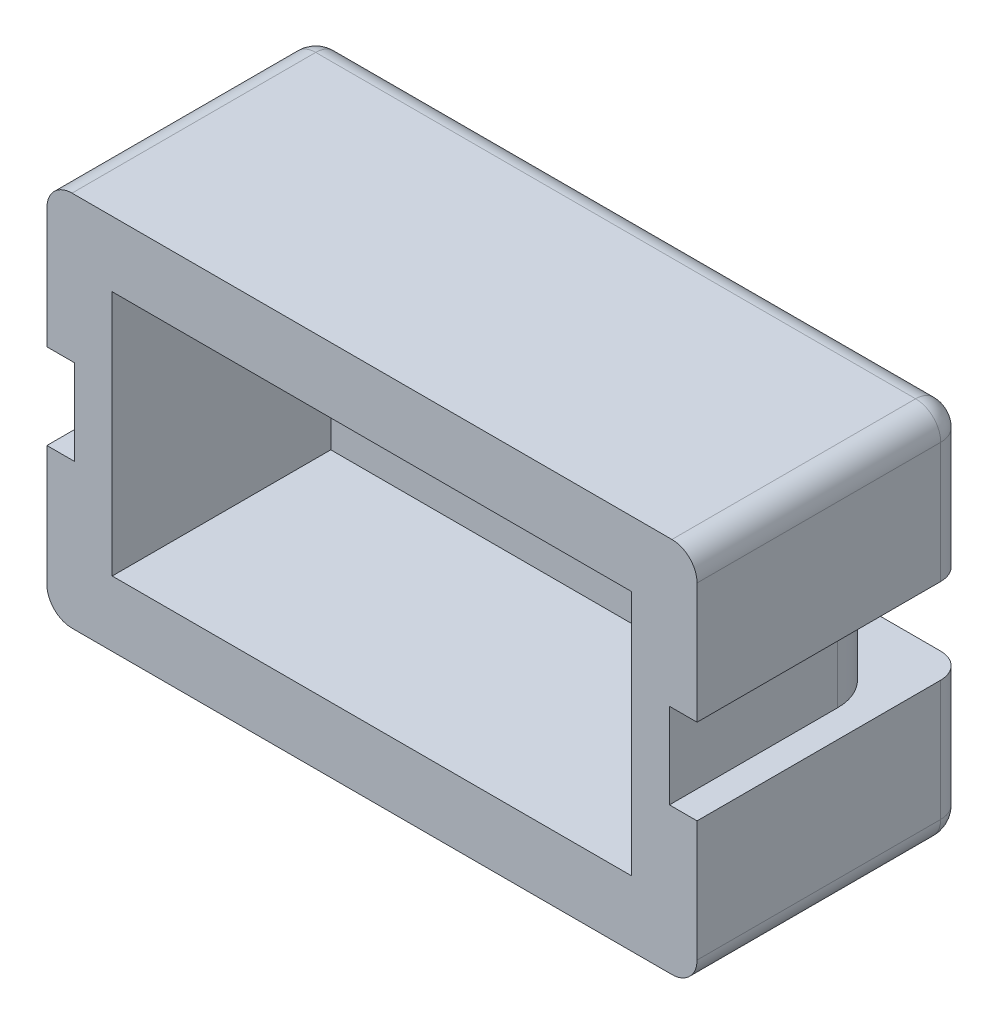
from build123d import *

# Parameters (mm, degrees)
SKETCH1_W                               = 12.94
SKETCH1_H                               = 7.5
BOSS_EXTRUDE1_DEPTH                     = 5.35
FILLET1_R                               = 0.5
SKETCH2_W                               = 10.34
SKETCH2_H                               = 4.9
CUT_EXTRUDE1_DEPTH                      = 4.35
SKETCH3_W                               = 10.34
SKETCH3_H                               = 1.6
CUT_EXTRUDE2_DEPTH                      = 2
SKETCH4_OUTSIDE_W                       = 18.116
SKETCH4_OUTSIDE_H                       = 10.526
CUT_EXTRUDE3_DEPTH                      = 1.6
FILLET2_R                               = 0.5
CUT_EXTRUDE4_CLEARANCE_FOR_TOP_DEPTH    = 0.05
CUT_EXTRUDE5_CLEARANCE_FOR_BOTTOM_DEPTH = 0.05
CUT_EXTRUDE6_CLEARANCE_ON_SIDES_DEPTH   = 1.7


with BuildPart() as part:
    # Sketch1 → Boss-Extrude1 (new body)
    with BuildSketch(Plane.XY):
        with Locations((0, -0.8)):
            Rectangle(SKETCH1_W, SKETCH1_H)
    extrude(amount=-BOSS_EXTRUDE1_DEPTH)

    # Fillet1
    fillet1_edges = [part.edges().sort_by_distance(p)[0] for p in [
        (-6.47, 2.95, -2.675),
        (6.47, 2.95, -2.675),
        (6.47, -4.55, -2.675),
        (-6.47, -4.55, -2.675),
    ]]
    fillet(fillet1_edges, radius=FILLET1_R)

    # Sketch2 → Cut-Extrude1 (cut)
    with BuildSketch(Plane.XY):
        with Locations((0, -0.8)):
            Rectangle(SKETCH2_W, SKETCH2_H)
    extrude(amount=-CUT_EXTRUDE1_DEPTH, mode=Mode.SUBTRACT)

    # Sketch3 → Cut-Extrude2 (cut, through all)
    with BuildSketch(Plane.XY.offset(-4.35)):
        with Locations((0, -0.8)):
            Rectangle(SKETCH3_W, SKETCH3_H)
    extrude(amount=-CUT_EXTRUDE2_DEPTH, mode=Mode.SUBTRACT)

    # Sketch4 outside → Cut-Extrude3 (cut)
    with BuildSketch(Plane.XZ.offset(1.6)):
        with Locations((0, -2.675)):
            Rectangle(SKETCH4_OUTSIDE_W, SKETCH4_OUTSIDE_H)
        with BuildLine():
            Line((5.97, -3.35), (5.97, 0))
            Line((5.97, 0), (-5.97, 0))
            Line((-5.97, 0), (-5.97, -3.35))
            ThreePointArc((-5.97, -3.35), (-5.677106781, -4.057106781), (-4.97, -4.35))
            Line((-4.97, -4.35), (-4.27, -4.35))
            Line((-4.27, -4.35), (4.27, -4.35))
            Line((4.27, -4.35), (4.97, -4.35))
            ThreePointArc((4.97, -4.35), (5.677106781, -4.057106781), (5.97, -3.35))
        make_face(mode=Mode.SUBTRACT)
    extrude(amount=-CUT_EXTRUDE3_DEPTH, mode=Mode.SUBTRACT)

    # Fillet2
    fillet2_edges = [part.edges().sort_by_distance(p)[0] for p in [
        (6.47, -2.825, -5.35),
        (0, 2.95, -5.35),
        (-6.47, 1.225, -5.35),
        (0, -4.55, -5.35),
        (6.323553391, -4.403553391, -5.35),
        (-6.323553391, -4.403553391, -5.35),
        (-6.323553391, 2.803553391, -5.35),
        (6.323553391, 2.803553391, -5.35),
        (6.47, 1.225, -5.35),
        (-6.47, -2.825, -5.35),
    ]]
    fillet(fillet2_edges, radius=FILLET2_R)

    # Sketch5 → Cut-Extrude4 - clearance for top (cut)
    with BuildSketch(Plane.XZ):
        with BuildLine():
            Line((-5.97, -5.35), (5.97, -5.35))
            ThreePointArc((5.97, -5.35), (6.323553391, -5.203553391), (6.47, -4.85))
            Line((6.47, -4.85), (6.47, 0))
            Line((6.47, 0), (5.97, 0))
            Line((5.97, 0), (5.97, -3.35))
            ThreePointArc((5.97, -3.35), (5.744596669, -3.982455532), (5.17, -4.329795897))
            Line((5.17, -4.329795897), (5.17, -4.35))
            Line((5.17, -4.35), (-5.17, -4.35))
            Line((-5.17, -4.35), (-5.17, -4.329795897))
            ThreePointArc((-5.17, -4.329795897), (-5.744596669, -3.982455532), (-5.97, -3.35))
            Line((-5.97, -3.35), (-5.97, 0))
            Line((-5.97, 0), (-6.47, 0))
            Line((-6.47, 0), (-6.47, -4.85))
            ThreePointArc((-6.47, -4.85), (-6.323553391, -5.203553391), (-5.97, -5.35))
        make_face()
    extrude(amount=-CUT_EXTRUDE4_CLEARANCE_FOR_TOP_DEPTH, mode=Mode.SUBTRACT)

    # Sketch6 → Cut-Extrude5 - clearance for bottom (cut)
    with BuildSketch(Plane(origin=(0, -1.6, 0), x_dir=(1, 0, 0), z_dir=(0, 1, 0))):
        with BuildLine():
            Line((5.97, 5.35), (-5.97, 5.35))
            ThreePointArc((-5.97, 5.35), (-6.323553391, 5.203553391), (-6.47, 4.85))
            Line((-6.47, 4.85), (-6.47, 0))
            Line((-6.47, 0), (-5.97, 0))
            Line((-5.97, 0), (-5.97, 3.35))
            ThreePointArc((-5.97, 3.35), (-5.744596669, 3.982455532), (-5.17, 4.329795897))
            Line((-5.17, 4.329795897), (-5.17, 4.35))
            Line((-5.17, 4.35), (5.17, 4.35))
            Line((5.17, 4.35), (5.17, 4.329795897))
            ThreePointArc((5.17, 4.329795897), (5.744596669, 3.982455532), (5.97, 3.35))
            Line((5.97, 3.35), (5.97, 0))
            Line((5.97, 0), (6.47, 0))
            Line((6.47, 0), (6.47, 4.85))
            ThreePointArc((6.47, 4.85), (6.323553391, 5.203553391), (5.97, 5.35))
        make_face()
    extrude(amount=-CUT_EXTRUDE5_CLEARANCE_FOR_BOTTOM_DEPTH, mode=Mode.SUBTRACT)

    # Sketch7 → Cut-Extrude6 - clearance on sides (cut)
    with BuildSketch(Plane.XZ.offset(-0.05)):
        with BuildLine():
            Line((-5.97, -5.4), (5.97, -5.4))
            ThreePointArc((5.97, -5.4), (6.35890873, -5.23890873), (6.52, -4.85))
            Line((6.52, -4.85), (6.52, 0.05))
            Line((6.52, 0.05), (5.92, 0.05))
            Line((5.92, 0.05), (5.92, -3.35))
            ThreePointArc((5.92, -3.35), (5.692841615, -3.9664414), (5.12, -4.288083152))
            Line((5.12, -4.288083152), (5.12, -4.3))
            Line((5.12, -4.3), (-5.12, -4.3))
            Line((-5.12, -4.3), (-5.12, -4.288083152))
            ThreePointArc((-5.12, -4.288083152), (-5.692841615, -3.9664414), (-5.92, -3.35))
            Line((-5.92, -3.35), (-5.92, 0.05))
            Line((-5.92, 0.05), (-6.52, 0.05))
            Line((-6.52, 0.05), (-6.52, -4.85))
            ThreePointArc((-6.52, -4.85), (-6.35890873, -5.23890873), (-5.97, -5.4))
        make_face()
    extrude(amount=CUT_EXTRUDE6_CLEARANCE_ON_SIDES_DEPTH, mode=Mode.SUBTRACT)


solid = part.part
